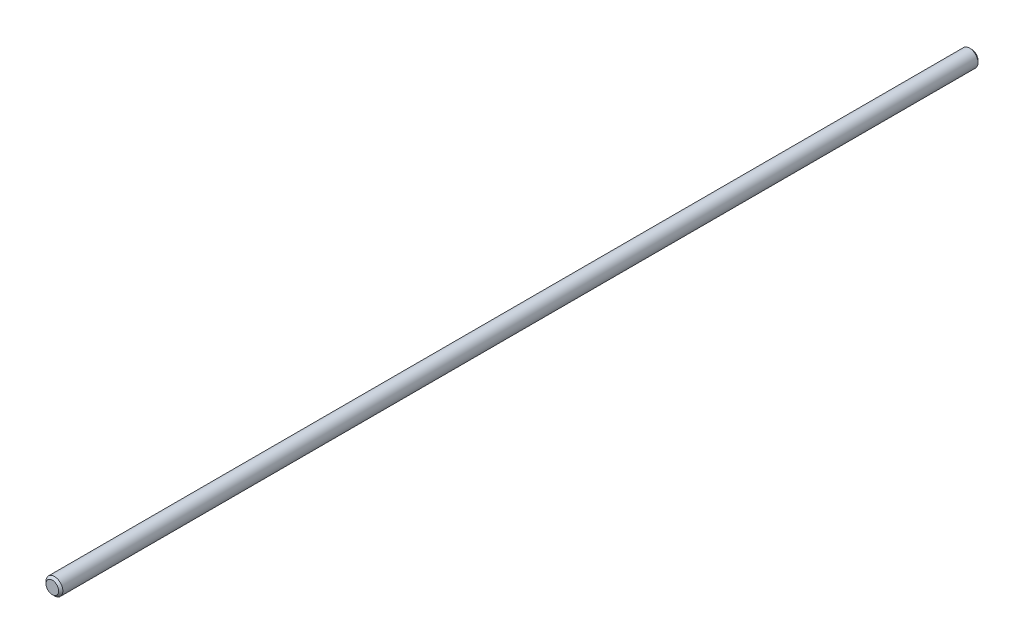
from build123d import *

# Parameters (mm, degrees)
SKETCH1_R           = 4
BOSS_EXTRUDE1_DEPTH = 437
CHAMFER1_SIZE       = 1


with BuildPart() as part:
    # Sketch1 → Boss-Extrude1 (new body)
    with BuildSketch(Plane.XY):
        Circle(SKETCH1_R)
    extrude(amount=BOSS_EXTRUDE1_DEPTH)

    # Chamfer1
    chamfer1_edges = [part.edges().sort_by_distance(p)[0] for p in [
        (-4, 0, 0),
        (-4, 0, 437),
    ]]
    chamfer(chamfer1_edges, length=CHAMFER1_SIZE)


solid = part.part
